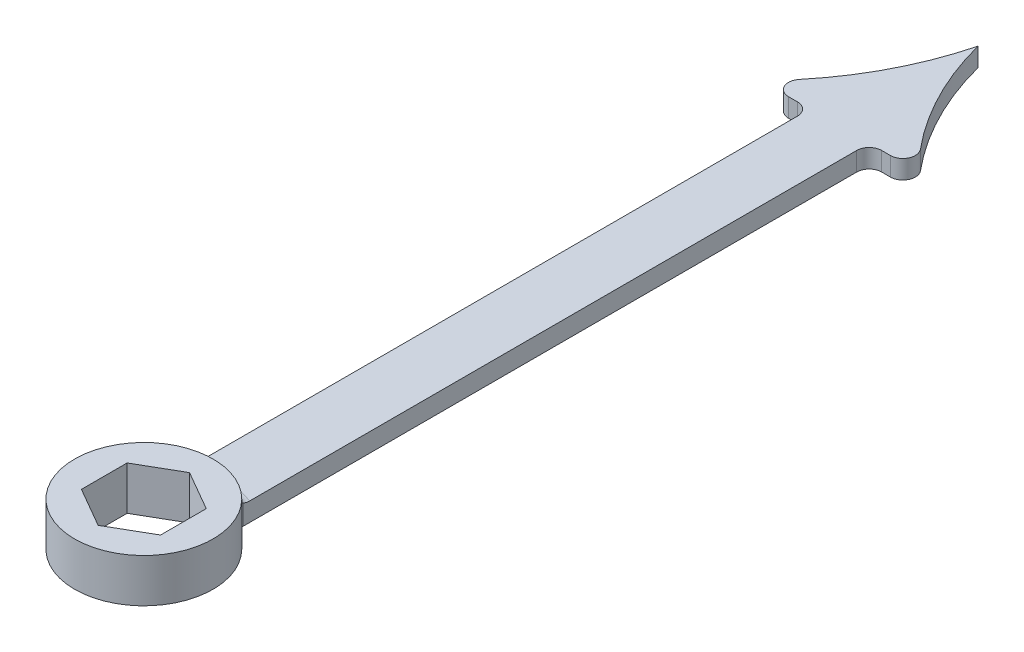
from build123d import *

# Parameters (mm, degrees)
SKETCH1_R           = 11.1125
BOSS_EXTRUDE1_DEPTH = 7
BOSS_EXTRUDE2_DEPTH = 3
FILLET1_R           = 2


with BuildPart() as part:
    # Sketch1 → Boss-Extrude1 (new body)
    with BuildSketch(Plane(origin=(0, 0, 0), x_dir=(1, 0, 0), z_dir=(0, 1, 0))):
        Circle(SKETCH1_R)
        Polygon((6.35, 3.666174209), (0, 7.332348419), (-6.35, 3.666174209), (-6.35, -3.666174209), (0, -7.332348419), (6.35, -3.666174209), align=None, mode=Mode.SUBTRACT)
    extrude(amount=BOSS_EXTRUDE1_DEPTH)

    # Sketch2 → Boss-Extrude2 (add)
    with BuildSketch(Plane(origin=(0, 0, 0), x_dir=(1, 0, 0), z_dir=(0, 1, 0))):
        with BuildLine():
            Line((-4.7625, 111.640231571), (-12.7, 111.640231571))
            ThreePointArc((-12.7, 111.640231571), (-4.861835295, 121.90235174), (0, 133.865231571))
            ThreePointArc((0, 133.865231571), (4.861835295, 121.90235174), (12.7, 111.640231571))
            Line((12.7, 111.640231571), (4.7625, 111.640231571))
            Line((4.7625, 111.640231571), (4.7625, 10.040231571))
            Line((4.7625, 10.040231571), (-4.7625, 10.040231571))
            Line((-4.7625, 10.040231571), (-4.7625, 111.640231571))
        make_face()
    extrude(amount=BOSS_EXTRUDE2_DEPTH)

    # Fillet1
    fillet1_edges = [part.edges().sort_by_distance(p)[0] for p in [
        (0, 3, -11.1125),
        (-4.7625, 1.5, -111.640231571),
        (-4.7625, 1.5, -10.040231571),
        (4.7625, 1.5, -10.040231571),
        (4.7625, 1.5, -111.640231571),
        (12.7, 1.5, -111.640231571),
        (-12.7, 1.5, -111.640231571),
    ]]
    fillet(fillet1_edges, radius=FILLET1_R)


solid = part.part
